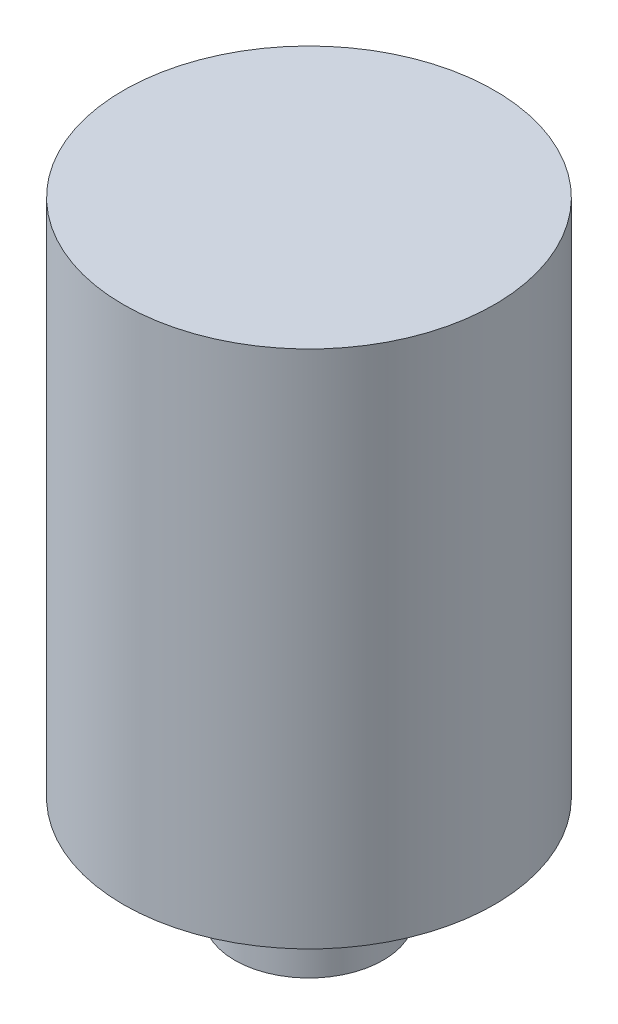
from build123d import *

# Parameters (mm, degrees)
SKETCH1_R           = 2
BOSS_EXTRUDE1_DEPTH = 2.8
SKETCH2_R           = 5
BOSS_EXTRUDE2_DEPTH = 14


with BuildPart() as part:
    # Sketch1 → Boss-Extrude1 (new body)
    with BuildSketch(Plane(origin=(0, 0, 0), x_dir=(1, 0, 0), z_dir=(0, 1, 0))):
        Circle(SKETCH1_R)
    extrude(amount=BOSS_EXTRUDE1_DEPTH)

    # Sketch2 → Boss-Extrude2 (add)
    with BuildSketch(Plane(origin=(0, 2.8, 0), x_dir=(-1, 0, 0), z_dir=(0, 1, 0))):
        Circle(SKETCH2_R)
    extrude(amount=BOSS_EXTRUDE2_DEPTH)


solid = part.part
